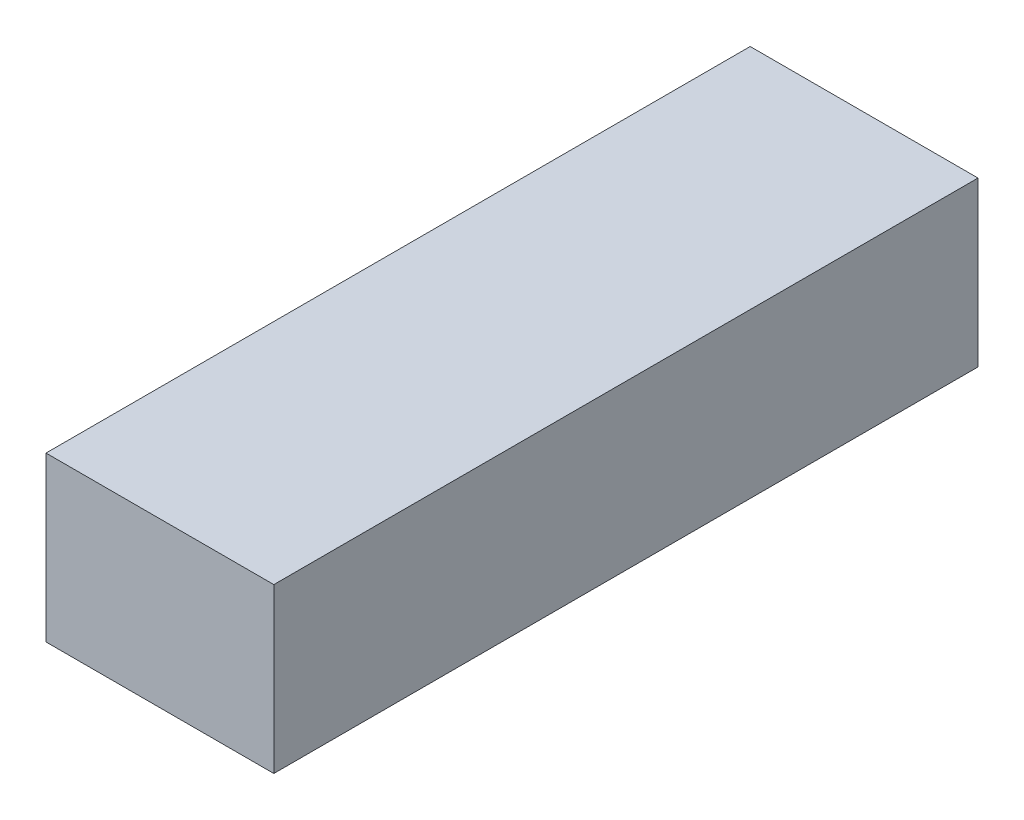
from build123d import *

# Parameters (mm, degrees)
SKETCH1_W           = 44
SKETCH1_H           = 31.6
BOSS_EXTRUDE1_DEPTH = 136


with BuildPart() as part:
    # Sketch1 → Boss-Extrude1 (new body)
    with BuildSketch(Plane.XY):
        Rectangle(SKETCH1_W, SKETCH1_H)
    extrude(amount=BOSS_EXTRUDE1_DEPTH)


solid = part.part
